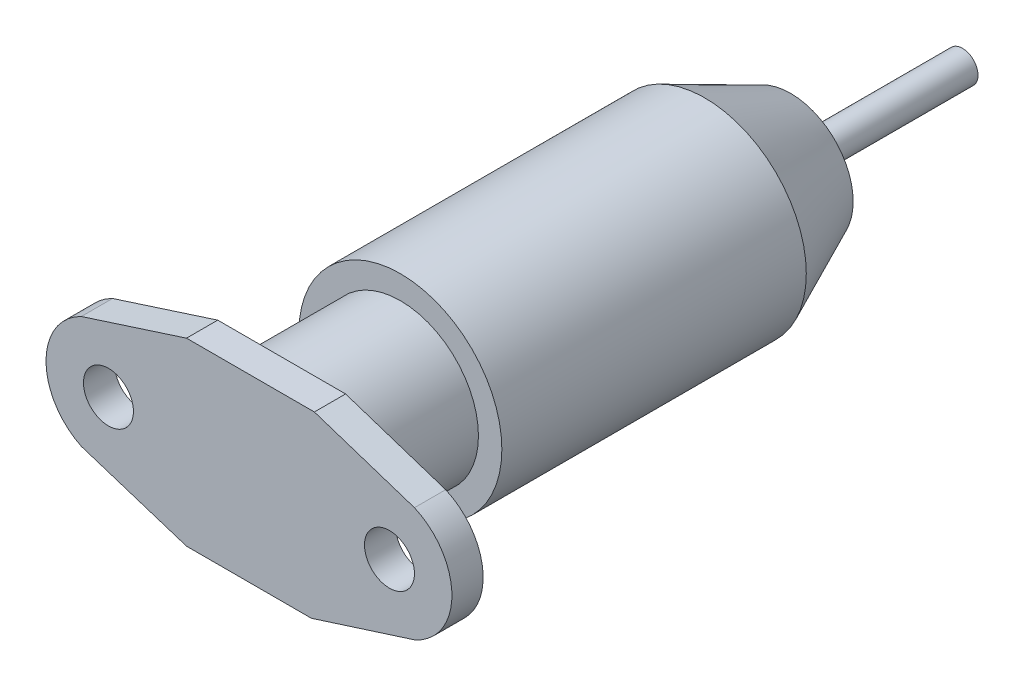
from build123d import *

# Parameters (mm, degrees)
SKETCH_1_R      = 1.6
EXTRUDE_1_DEPTH = 2
SKETCH_2_R      = 5
EXTRUDE_2_DEPTH = 7.7
SKETCH_3_R      = 6.5
SKETCH_3_R_2    = 5
EXTRUDE_3_DEPTH = 19.5
SKETCH_4_R      = 4
SKETCH_5_R      = 1
EXTRUDE_4_DEPTH = 11


with BuildPart() as part:
    # 草图1 → 凸台-拉伸1 (new body)
    with BuildSketch(Plane.XY):
        with BuildLine():
            Line((0.933236487, 5.304565516), (-7.256880734, 5.304565516))
            Line((-7.256880734, 5.304565516), (-13.994027653, 3.137664263))
            ThreePointArc((-13.994027653, 3.137664263), (-16.256880734, -0.465434484), (-13.994027653, -4.068533231))
            Line((-13.994027653, -4.068533231), (-7.256880734, -6.235434484))
            Line((-7.256880734, -6.235434484), (0.743119266, -6.235434484))
            Line((0.743119266, -6.235434484), (7.344389981, -4.130940192))
            ThreePointArc((7.344389981, -4.130940192), (9.743119266, -0.465434484), (7.344389981, 3.200071224))
            Line((7.344389981, 3.200071224), (0.933236487, 5.304565516))
        make_face()
        with Locations((-12.256880734, -0.465434484)):
            Circle(SKETCH_1_R, mode=Mode.SUBTRACT)
        with Locations((5.743119266, -0.465434484)):
            Circle(SKETCH_1_R, mode=Mode.SUBTRACT)
    extrude(amount=EXTRUDE_1_DEPTH)

    # 草图2 → 凸台-拉伸2 (add)
    with BuildSketch(Plane(origin=(0, 0, 0), x_dir=(-1, 0, 0), z_dir=(0, 0, -1))):
        with Locations((3.256880734, -0.465434484)):
            Circle(SKETCH_2_R)
    extrude(amount=EXTRUDE_2_DEPTH)

    # 草图3 → 凸台-拉伸3 (add)
    with BuildSketch(Plane(origin=(0, 0, -7.7), x_dir=(-1, 0, 0), z_dir=(0, 0, -1))):
        with Locations((3.256880734, -0.465434484)):
            Circle(SKETCH_3_R)
        with Locations((3.256880734, -0.465434484)):
            Circle(SKETCH_3_R_2, mode=Mode.SUBTRACT)
        with BuildLine():
            ThreePointArc((-1.743119266, -0.465434484), (3.256880734, -5.465434484), (8.256880734, -0.465434484))
            Line((8.256880734, -0.465434484), (-1.743119266, -0.465434484))
        make_face()
        with BuildLine():
            Line((-1.743119266, -0.465434484), (8.256880734, -0.465434484))
            ThreePointArc((8.256880734, -0.465434484), (3.256880734, 4.534565516), (-1.743119266, -0.465434484))
        make_face()
    extrude(amount=EXTRUDE_3_DEPTH)

    # 草图4 → section 0 of loft_1
    with BuildSketch(Plane(origin=(0, 0, -32.7), x_dir=(-1, 0, 0), z_dir=(0, 0, -1)), mode=Mode.PRIVATE) as loft_1_s0:
        with Locations((3.256880734, -0.465434484)):
            Circle(SKETCH_4_R)
    # loft up to a face of the part (loft_1)
    loft([loft_1_s0.sketch, part.faces().sort_by_distance((-3.256880734, -0.465434484, -27.2))[0]])

    # 草图5 → 凸台-拉伸4 (add)
    with BuildSketch(Plane(origin=(0, 0, -32.7), x_dir=(-1, 0, 0), z_dir=(0, 0, -1))):
        with Locations((3.256880734, -0.465434484)):
            Circle(SKETCH_5_R)
    extrude(amount=EXTRUDE_4_DEPTH)


solid = part.part
